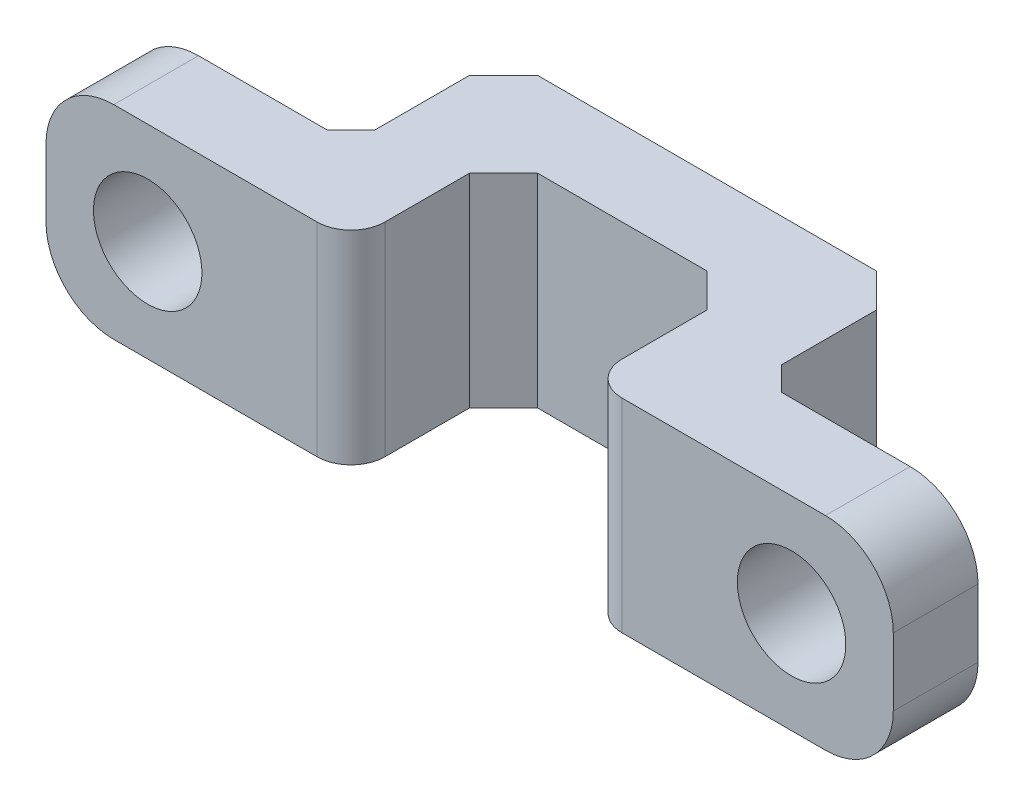
from build123d import *

# Parameters (mm, degrees)
SKETCH2_W           = 6.5
SKETCH2_H           = 2.5
SKETCH2_W_2         = 7
BOSS_EXTRUDE2_DEPTH = 6
SKETCH3_R           = 1.6
CUT_EXTRUDE1_DEPTH  = 3.5
CHAMFER1_SIZE       = 1
FILLET1_R           = 2
FILLET2_R           = 1
CHAMFER2_SIZE       = 0.7


with BuildPart() as part:
    # Sketch2 → Boss-Extrude2 (new body)
    with BuildSketch(Plane(origin=(0, 0, 0), x_dir=(1, 0, 0), z_dir=(0, 1, 0))):
        with Locations((-9.25, -4.5)):
            Rectangle(SKETCH2_W, SKETCH2_H)
        Polygon((-3.5, -5.75), (-3.5, -1.25), (-3.5, 1.25), (-6, 1.25), (-6, -3.25), (-6, -5.75), align=None)
        Rectangle(SKETCH2_W_2, SKETCH2_H)
        Polygon((3.5, 1.25), (3.5, -1.25), (3.5, -5.75), (6, -5.75), (6, -3.25), (6, 1.25), align=None)
        with Locations((9.25, -4.5)):
            Rectangle(SKETCH2_W, SKETCH2_H)
    extrude(amount=BOSS_EXTRUDE2_DEPTH)

    # Sketch3 → Cut-Extrude1 (cut, through all)
    with BuildSketch(Plane(origin=(0, 0, 3.25), x_dir=(-1, 0, 0), z_dir=(0, 0, -1))):
        with Locations((-9.5, 3)):
            Circle(SKETCH3_R)
        with Locations((9.5, 3)):
            Circle(SKETCH3_R)
    extrude(amount=-CUT_EXTRUDE1_DEPTH, mode=Mode.SUBTRACT)

    # Chamfer1
    chamfer1_edges = [part.edges().sort_by_distance(p)[0] for p in [
        (-6, 3, -1.25),
        (6, 3, -1.25),
        (3.5, 3, 1.25),
        (-3.5, 3, 1.25),
    ]]
    chamfer(chamfer1_edges, length=CHAMFER1_SIZE)

    # Fillet1
    fillet1_edges = [part.edges().sort_by_distance(p)[0] for p in [
        (12.5, 0, 4.5),
        (-12.5, 0, 4.5),
        (12.5, 6, 4.5),
        (-12.5, 6, 4.5),
    ]]
    fillet(fillet1_edges, radius=FILLET1_R)

    # Fillet2
    fillet2_edges = [part.edges().sort_by_distance(p)[0] for p in [
        (3.5, 3, 5.75),
        (-3.5, 3, 5.75),
    ]]
    fillet(fillet2_edges, radius=FILLET2_R)

    # Chamfer2
    chamfer2_edges = [part.edges().sort_by_distance(p)[0] for p in [
        (-6, 3, 3.25),
        (6, 3, 3.25),
    ]]
    chamfer(chamfer2_edges, length=CHAMFER2_SIZE)


solid = part.part
